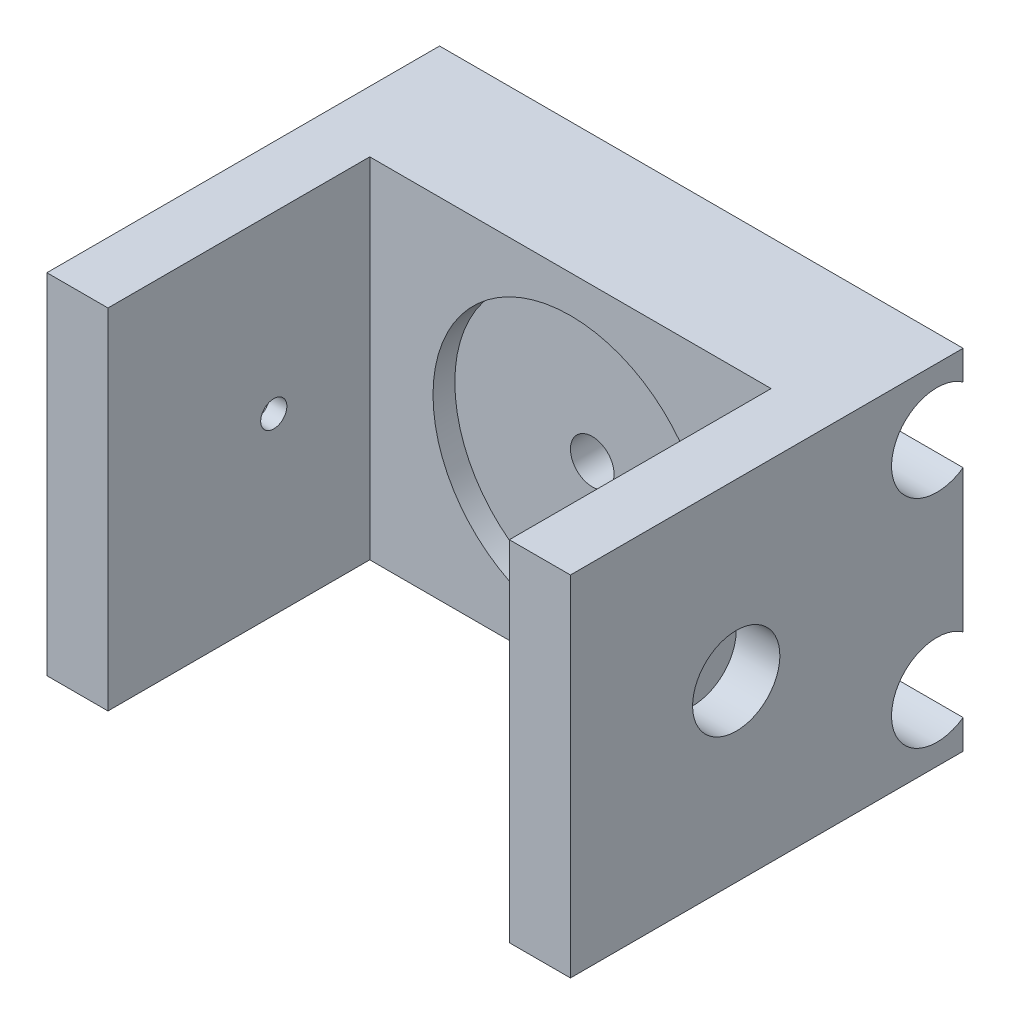
from build123d import *

# Parameters (mm, degrees)
SKETCH1_W               = 60
SKETCH1_H               = 40
BOSS_EXTRUDE1_DEPTH     = 15
SKETCH3_R               = 5.2
CUT_EXTRUDE1_DEPTH      = 63
SKETCH4_W               = 7
SKETCH4_H               = 40
BOSS_EXTRUDE2_DEPTH     = 30
SKETCH5_R               = 5
CUT_EXTRUDE2_DEPTH      = 5
SKETCH6_R               = 5
CUT_EXTRUDE3_DEPTH      = 4
SKETCH7_R               = 2.5
CUT_EXTRUDE4_DEPTH      = 42
SKETCH8_R               = 15.75
CUT_EXTRUDE5_DEPTH      = 2.5
SKETCH9_R               = 1.5
CUT_EXTRUDE6_DEPTH      = 54
CUT_EXTRUDE6_DEPTH_BACK = 8


with BuildPart() as part:
    # Sketch1 → Boss-Extrude1 (new body)
    with BuildSketch(Plane.XY):
        with Locations((12.222222222, 0.91503268)):
            Rectangle(SKETCH1_W, SKETCH1_H)
    extrude(amount=BOSS_EXTRUDE1_DEPTH)

    # Sketch3 → Cut-Extrude1 (cut)
    with BuildSketch(Plane(origin=(42.222222222, 0, 0), x_dir=(0, 0, -1), z_dir=(1, 0, 0))):
        with Locations((-3, -11.48496732)):
            Circle(SKETCH3_R)
        with Locations((-3, 13.31503268)):
            Circle(SKETCH3_R)
    extrude(amount=-CUT_EXTRUDE1_DEPTH, mode=Mode.SUBTRACT)

    # Sketch4 → Boss-Extrude2 (add)
    with BuildSketch(Plane.XY.offset(15)):
        with Locations((38.722222222, 0.91503268)):
            Rectangle(SKETCH4_W, SKETCH4_H)
    boss_extrude2 = extrude(amount=BOSS_EXTRUDE2_DEPTH)

    # Sketch5 → Cut-Extrude2 (cut)
    with BuildSketch(Plane(origin=(42.222222222, 0, 0), x_dir=(0, 0, -1), z_dir=(1, 0, 0))):
        with Locations((-26, 0.91503268)):
            Circle(SKETCH5_R)
    cut_extrude2 = extrude(amount=-CUT_EXTRUDE2_DEPTH, mode=Mode.SUBTRACT)

    # Mirror1: Boss-Extrude2, Cut-Extrude2 across plane
    add(boss_extrude2.mirror(Plane.ZY.offset(-12.222222222)))
    add(cut_extrude2.mirror(Plane.ZY.offset(-12.222222222)), mode=Mode.SUBTRACT)

    # Sketch6 → Cut-Extrude3 (cut)
    with BuildSketch(Plane(origin=(0, 0, 0), x_dir=(-1, 0, 0), z_dir=(0, 0, -1))):
        with Locations((-12.222222222, 0.91503268)):
            Circle(SKETCH6_R)
    extrude(amount=-CUT_EXTRUDE3_DEPTH, mode=Mode.SUBTRACT)

    # Sketch7 → Cut-Extrude4 (cut, through all)
    with BuildSketch(Plane(origin=(0, 0, 4), x_dir=(-1, 0, 0), z_dir=(0, 0, -1))):
        with Locations((-12.222222222, 0.91503268)):
            Circle(SKETCH7_R)
    extrude(amount=-CUT_EXTRUDE4_DEPTH, mode=Mode.SUBTRACT)

    # Sketch8 → Cut-Extrude5 (cut)
    with BuildSketch(Plane.XY.offset(15)):
        with Locations((12.222222222, 0.91503268)):
            Circle(SKETCH8_R)
    extrude(amount=-CUT_EXTRUDE5_DEPTH, mode=Mode.SUBTRACT)

    # Sketch9 → Cut-Extrude6 (cut, two sides)
    with BuildSketch(Plane.ZY.offset(-35.222222222)) as cut_extrude6_sk:
        with Locations((26, 0.91503268)):
            Circle(SKETCH9_R)
    extrude(amount=CUT_EXTRUDE6_DEPTH, mode=Mode.SUBTRACT)
    extrude(cut_extrude6_sk.sketch, amount=-CUT_EXTRUDE6_DEPTH_BACK, mode=Mode.SUBTRACT)


solid = part.part
